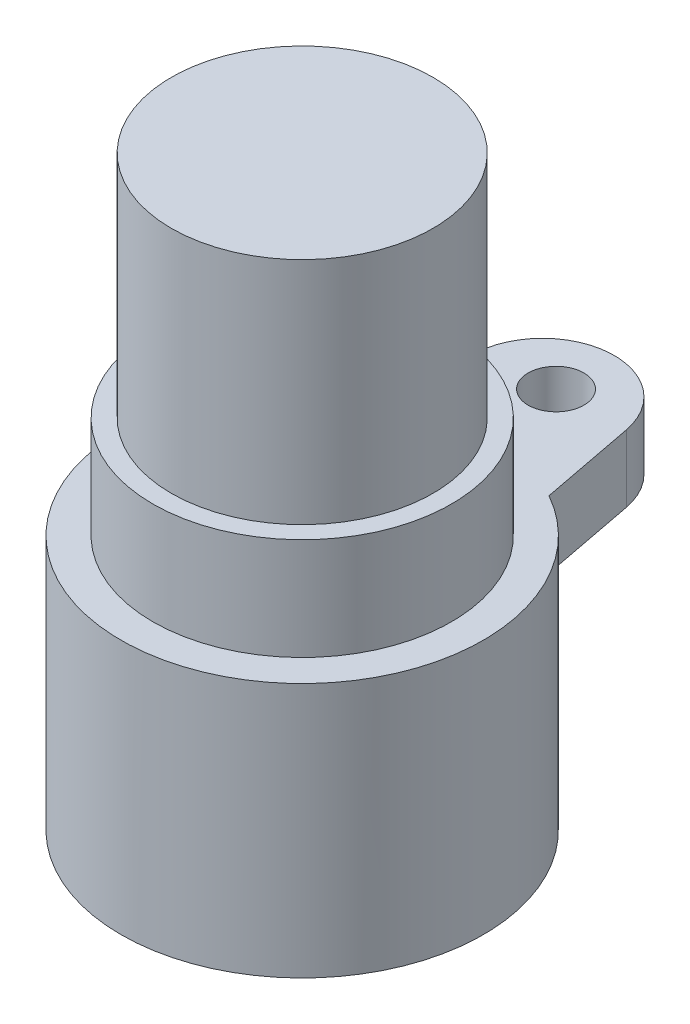
from build123d import *

# Parameters (mm, degrees)
SKETCH1_R           = 13.5
BOSS_EXTRUDE1_DEPTH = 19
BOSS_EXTRUDE2_START = 19
SKETCH1_3_R         = 11.125
BOSS_EXTRUDE2_DEPTH = 7.6
BOSS_EXTRUDE3_START = 26.6
SKETCH1_4_R         = 9.75
BOSS_EXTRUDE3_DEPTH = 17.1
BOSS_EXTRUDE4_START = 19
SKETCH1_5_R         = 2.08
BOSS_EXTRUDE4_DEPTH = 6
CHAMFER1_SIZE       = 1


with BuildPart() as part:
    # Sketch1 → Boss-Extrude1 (new body)
    with BuildSketch(Plane(origin=(0, 0, 0), x_dir=(1, 0, 0), z_dir=(0, 1, 0))):
        Circle(SKETCH1_R)
    extrude(amount=BOSS_EXTRUDE1_DEPTH)

    # Sketch1_3 → Boss-Extrude2 (add)
    with BuildSketch(Plane(origin=(0, 0, 0), x_dir=(1, 0, 0), z_dir=(0, 1, 0)).offset(BOSS_EXTRUDE2_START)):
        Circle(SKETCH1_3_R)
    extrude(amount=BOSS_EXTRUDE2_DEPTH)

    # Sketch1_4 → Boss-Extrude3 (add)
    with BuildSketch(Plane(origin=(0, 0, 0), x_dir=(1, 0, 0), z_dir=(0, 1, 0)).offset(BOSS_EXTRUDE3_START)):
        Circle(SKETCH1_4_R)
    extrude(amount=BOSS_EXTRUDE3_DEPTH)

    # Sketch1_5 → Boss-Extrude4 (add)
    with BuildSketch(Plane(origin=(0, 0, 0), x_dir=(1, 0, 0), z_dir=(0, 1, 0)).offset(BOSS_EXTRUDE4_START)):
        with BuildLine():
            ThreePointArc((5.25, 18.912204045), (0, 23.2511033), (-5.25, 18.912204045))
            Line((-5.25, 18.912204045), (-6.620548595, 11.765132227))
            ThreePointArc((-6.620548595, 11.765132227), (0, 13.5), (6.620548595, 11.765132227))
            Line((6.620548595, 11.765132227), (5.25, 18.912204045))
        make_face()
        with Locations((0, 18.912204045)):
            Circle(SKETCH1_5_R, mode=Mode.SUBTRACT)
    extrude(amount=-BOSS_EXTRUDE4_DEPTH)

    # Chamfer1
    chamfer1_edges = [part.edges().sort_by_distance(p)[0] for p in [
        (0, 13, -23.2511033),
        (5.935274297, 13, -15.338668136),
        (-5.935274297, 13, -15.338668136),
    ]]
    chamfer(chamfer1_edges, length=CHAMFER1_SIZE)


solid = part.part
